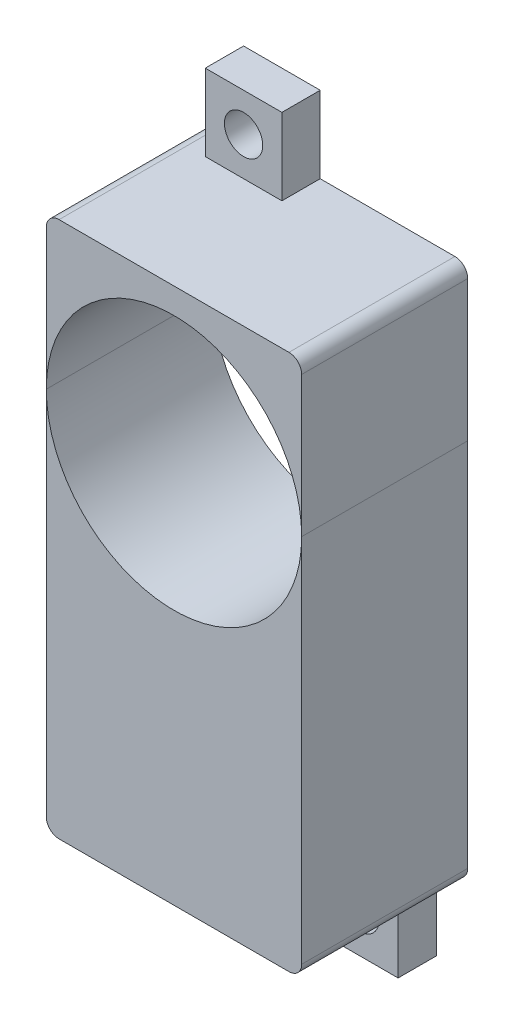
from build123d import *

# Parameters (mm, degrees)
SKETCH1_R             = 1.5
BOSS_EXTRUDE2_DEPTH   = 6.5
BOSS_EXTRUDE2_2_DEPTH = 6.5
SKETCH3_W             = 6
SKETCH3_H             = 6
CUT_EXTRUDE1_DEPTH    = 10
SKETCH4_W             = 6
SKETCH4_H             = 6.157083321
CUT_EXTRUDE2_DEPTH    = 10


with BuildPart() as part:
    # Sketch1 → Boss-Extrude2 (new body, symmetric)
    with BuildSketch(Plane.XY):
        with BuildLine():
            ThreePointArc((10, 0), (0, -10), (-10, 0))
            Line((-10, 0), (-10, -29))
            ThreePointArc((-10, -29), (-9.707106781, -29.707106781), (-9, -30))
            Line((-9, -30), (1.55, -30))
            Line((1.55, -30), (1.55, -36.157083321))
            Line((1.55, -36.157083321), (7.55, -36.157083321))
            Line((7.55, -36.157083321), (7.55, -30))
            Line((7.55, -30), (9, -30))
            ThreePointArc((9, -30), (9.707106781, -29.707106781), (10, -29))
            Line((10, -29), (10, 0))
        make_face()
        with Locations((4.55, -33)):
            Circle(SKETCH1_R, mode=Mode.SUBTRACT)
    extrude(amount=BOSS_EXTRUDE2_DEPTH, both=True)

    # Sketch4 → Cut-Extrude2 (cut)
    with BuildSketch(Plane.XY.offset(6.5)):
        with Locations((4.55, -33.078541661)):
            Rectangle(SKETCH4_W, SKETCH4_H)
    extrude(amount=-CUT_EXTRUDE2_DEPTH, mode=Mode.SUBTRACT)


with BuildPart() as body_2:
    # Sketch1 → Boss-Extrude2 2 (new body, symmetric)
    with BuildSketch(Plane.XY):
        with BuildLine():
            Line((-10, 11), (-10, 0))
            ThreePointArc((-10, 0), (0, 10), (10, 0))
            Line((10, 0), (10, 11))
            ThreePointArc((10, 11), (9.707106781, 11.707106781), (9, 12))
            Line((9, 12), (-1.55, 12))
            Line((-1.55, 12), (-1.55, 18))
            Line((-1.55, 18), (-7.55, 18))
            Line((-7.55, 18), (-7.55, 12))
            Line((-7.55, 12), (-9, 12))
            ThreePointArc((-9, 12), (-9.707106781, 11.707106781), (-10, 11))
        make_face()
        with Locations((-4.55, 15)):
            Circle(SKETCH1_R, mode=Mode.SUBTRACT)
    extrude(amount=BOSS_EXTRUDE2_2_DEPTH, both=True)

    # Sketch3 → Cut-Extrude1 (cut)
    with BuildSketch(Plane.XY.offset(6.5)):
        with Locations((-4.55, 15)):
            Rectangle(SKETCH3_W, SKETCH3_H)
    extrude(amount=-CUT_EXTRUDE1_DEPTH, mode=Mode.SUBTRACT)


solid = Compound([part.part, body_2.part])
